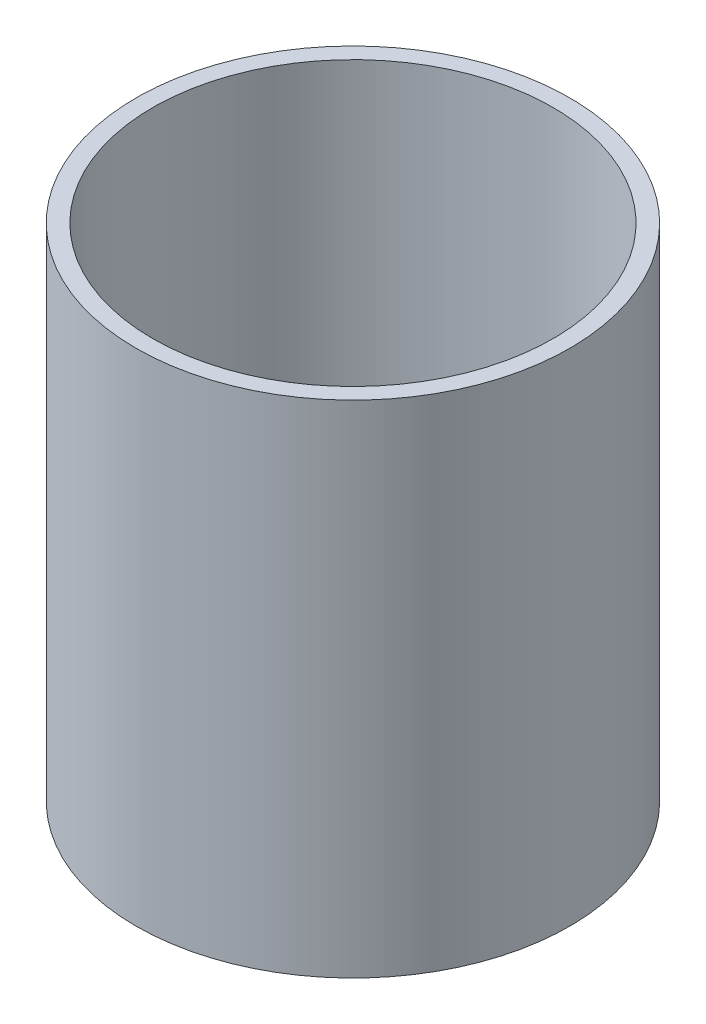
from build123d import *

# Parameters (mm, degrees)
SKETCH1_R           = 26
SKETCH1_R_2         = 24
BOSS_EXTRUDE1_DEPTH = 60


with BuildPart() as part:
    # Sketch1 → Boss-Extrude1 (new body)
    with BuildSketch(Plane(origin=(0, 0, 0), x_dir=(1, 0, 0), z_dir=(0, 1, 0))):
        Circle(SKETCH1_R)
        Circle(SKETCH1_R_2, mode=Mode.SUBTRACT)
    extrude(amount=BOSS_EXTRUDE1_DEPTH)


solid = part.part
